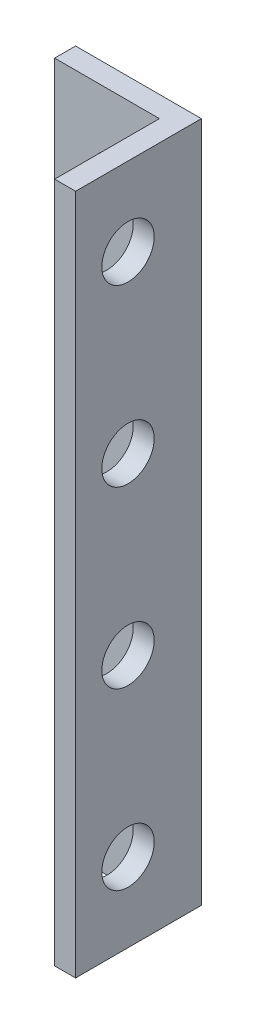
from build123d import *

# Parameters (mm, degrees)
SKETCH1_W           = 7.2
SKETCH1_H           = 39
SKETCH1_R           = 1.5
BOSS_EXTRUDE1_DEPTH = 1.2
SKETCH2_W           = 1.2
SKETCH2_H           = 39
BOSS_EXTRUDE2_DEPTH = 6
CUT_EXTRUDE1_REACH  = 3.2
SKETCH3_R           = 1.5


with BuildPart() as part:
    # Sketch1 → Boss-Extrude1 (new body)
    with BuildSketch(Plane.XY):
        Rectangle(SKETCH1_W, SKETCH1_H)
        with Locations((0, -5)):
            Circle(SKETCH1_R, mode=Mode.SUBTRACT)
        with Locations((0, -15)):
            Circle(SKETCH1_R, mode=Mode.SUBTRACT)
        with Locations((0, 15)):
            Circle(SKETCH1_R, mode=Mode.SUBTRACT)
        with Locations((0, 5)):
            Circle(SKETCH1_R, mode=Mode.SUBTRACT)
    extrude(amount=BOSS_EXTRUDE1_DEPTH)

    # Sketch2 → Boss-Extrude2 (add)
    with BuildSketch(Plane.XY.offset(1.2)):
        with Locations((3, 0)):
            Rectangle(SKETCH2_W, SKETCH2_H)
    extrude(amount=BOSS_EXTRUDE2_DEPTH)

    # Sketch3 → Cut-Extrude1 (cut, up to next)
    with BuildSketch(Plane.ZY.offset(-2.4), mode=Mode.PRIVATE) as cut_extrude1_sk1:
        with Locations((4.2, 15)):
            Circle(SKETCH3_R)
    cut_extrude1_tool1 = extrude(cut_extrude1_sk1.sketch, amount=-CUT_EXTRUDE1_REACH, mode=Mode.PRIVATE) & part.part
    add(cut_extrude1_tool1.solids().sort_by_distance((2.4, 15, 4.2))[0], mode=Mode.SUBTRACT)
    # Sketch3 → Cut-Extrude1 (cut, up to next)
    with BuildSketch(Plane.ZY.offset(-2.4), mode=Mode.PRIVATE) as cut_extrude1_sk2:
        with Locations((4.2, 5)):
            Circle(SKETCH3_R)
    cut_extrude1_tool2 = extrude(cut_extrude1_sk2.sketch, amount=-CUT_EXTRUDE1_REACH, mode=Mode.PRIVATE) & part.part
    add(cut_extrude1_tool2.solids().sort_by_distance((2.4, 5, 4.2))[0], mode=Mode.SUBTRACT)
    # Sketch3 → Cut-Extrude1 (cut, up to next)
    with BuildSketch(Plane.ZY.offset(-2.4), mode=Mode.PRIVATE) as cut_extrude1_sk3:
        with Locations((4.2, -5)):
            Circle(SKETCH3_R)
    cut_extrude1_tool3 = extrude(cut_extrude1_sk3.sketch, amount=-CUT_EXTRUDE1_REACH, mode=Mode.PRIVATE) & part.part
    add(cut_extrude1_tool3.solids().sort_by_distance((2.4, -5, 4.2))[0], mode=Mode.SUBTRACT)
    # Sketch3 → Cut-Extrude1 (cut, up to next)
    with BuildSketch(Plane.ZY.offset(-2.4), mode=Mode.PRIVATE) as cut_extrude1_sk4:
        with Locations((4.2, -15)):
            Circle(SKETCH3_R)
    cut_extrude1_tool4 = extrude(cut_extrude1_sk4.sketch, amount=-CUT_EXTRUDE1_REACH, mode=Mode.PRIVATE) & part.part
    add(cut_extrude1_tool4.solids().sort_by_distance((2.4, -15, 4.2))[0], mode=Mode.SUBTRACT)


solid = part.part
